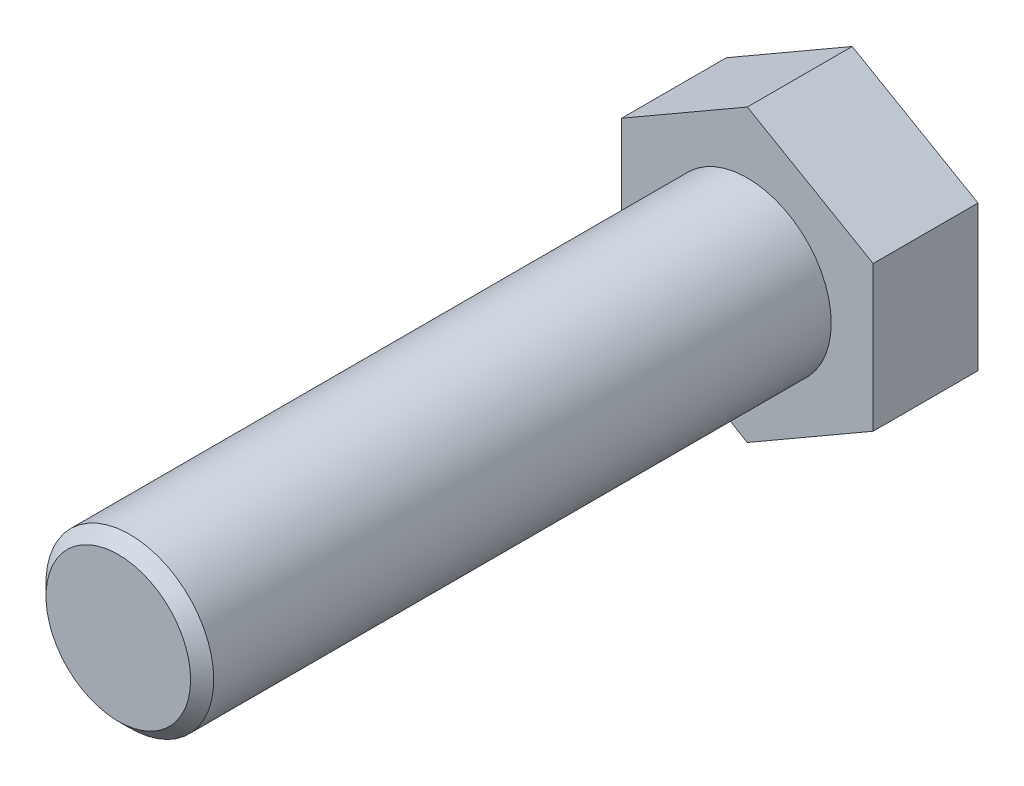
from build123d import *

# Parameters (mm, degrees)
EXTRUDE_1_DEPTH = 7.5
SKETCH_2_R      = 6
EXTRUDE_2_DEPTH = 45
CHAMFER_1_SIZE  = 0.828


with BuildPart() as part:
    # Эскиз1 → Бобышка-Вытянуть1 (new body)
    with BuildSketch(Plane.XY):
        Polygon((0, 10.392304845), (-9, 5.196152423), (-9, -5.196152423), (0, -10.392304845), (9, -5.196152423), (9, 5.196152423), align=None)
    extrude(amount=EXTRUDE_1_DEPTH)

    # Эскиз2 → Бобышка-Вытянуть2 (add)
    with BuildSketch(Plane.XY.offset(7.5)):
        Circle(SKETCH_2_R)
    extrude(amount=EXTRUDE_2_DEPTH)

    # Фаска1
    chamfer_1_edges = [part.edges().sort_by_distance(p)[0] for p in [
        (-6, 0, 52.5),
    ]]
    chamfer(chamfer_1_edges, length=CHAMFER_1_SIZE)


solid = part.part
